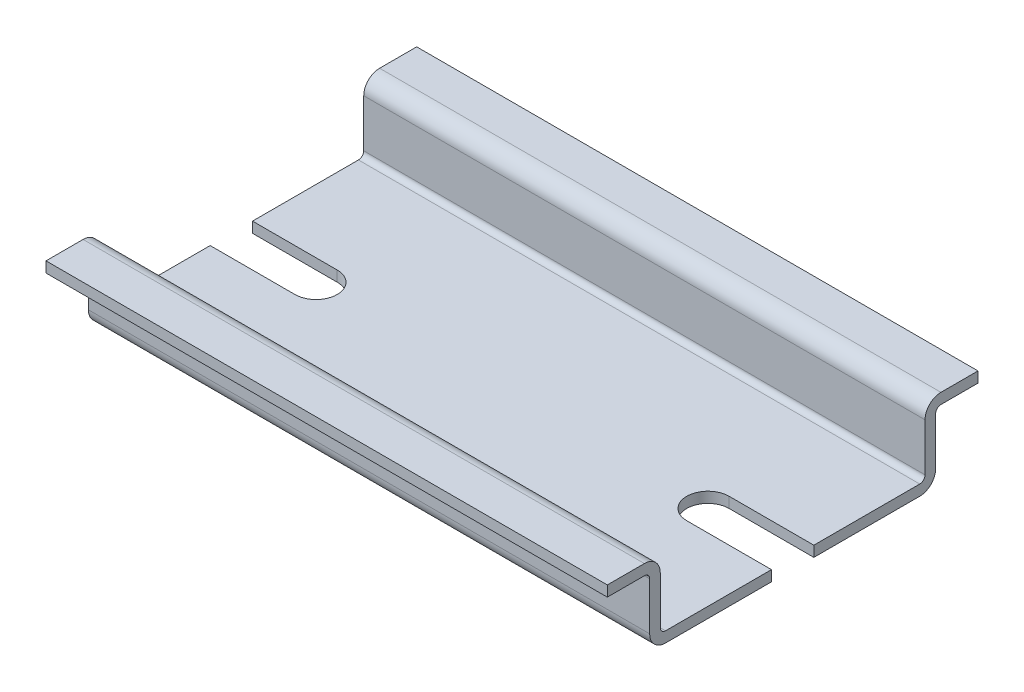
from build123d import *

# Parameters (mm, degrees)
BOSS_EXTRUDE1_DEPTH   = 26.5
CUT_EXTRUDE1_DEPTH    = 2
MIRROR17_COPY_1_DEPTH = 26.5
MIRROR17_COPY_2_DEPTH = 2


with BuildPart() as part:
    # Sketch1 → Boss-Extrude1 (new body)
    with BuildSketch(Plane(origin=(0, 0, 0), x_dir=(0, 0, -1), z_dir=(1, 0, 0))):
        with BuildLine():
            Line((0, 0), (-12, 0))
            ThreePointArc((-12, 0), (-13.060660172, 0.439339828), (-13.5, 1.5))
            Line((-13.5, 1.5), (-13.5, 6))
            ThreePointArc((-13.5, 6), (-13.646446609, 6.353553391), (-14, 6.5))
            Line((-14, 6.5), (-17.5, 6.5))
            Line((-17.5, 6.5), (-17.5, 7.5))
            Line((-17.5, 7.5), (-14, 7.5))
            ThreePointArc((-14, 7.5), (-12.939339828, 7.060660172), (-12.5, 6))
            Line((-12.5, 6), (-12.5, 1.5))
            ThreePointArc((-12.5, 1.5), (-12.353553391, 1.146446609), (-12, 1))
            Line((-12, 1), (0, 1))
            Line((0, 1), (0, 0))
        make_face()
    boss_extrude1 = extrude(amount=BOSS_EXTRUDE1_DEPTH)

    # Sketch3 → Cut-Extrude1 (cut, through all)
    with BuildSketch(Plane(origin=(0, 1, 0), x_dir=(1, 0, 0), z_dir=(0, 1, 0))):
        with BuildLine():
            Line((26.5, 0), (16.5, 0))
            ThreePointArc((16.5, 0), (17.085786438, -1.414213562), (18.5, -2))
            Line((18.5, -2), (26.5, -2))
            Line((26.5, -2), (26.5, 0))
        make_face()
    cut_extrude1 = extrude(amount=-CUT_EXTRUDE1_DEPTH, mode=Mode.SUBTRACT)

    # Mirror16: Boss-Extrude1, Cut-Extrude1 across plane
    add(boss_extrude1.mirror(Plane(origin=(0, 0, 0), x_dir=(0, 0, 1), z_dir=(1, 0, 0))))
    add(cut_extrude1.mirror(Plane(origin=(0, 0, 0), x_dir=(0, 0, 1), z_dir=(1, 0, 0))), mode=Mode.SUBTRACT)

    # Mirror17: Boss-Extrude1, Cut-Extrude1 across plane
    add(boss_extrude1.mirror(Plane.XY))
    add(cut_extrude1.mirror(Plane.XY), mode=Mode.SUBTRACT)

    # Mirror17 copy 1 sketch → Mirror17 copy 1 (add)
    with BuildSketch(Plane.ZY):
        with BuildLine():
            Line((0, 0), (-12, 0))
            ThreePointArc((-12, 0), (-13.060660172, 0.439339828), (-13.5, 1.5))
            Line((-13.5, 1.5), (-13.5, 6))
            ThreePointArc((-13.5, 6), (-13.646446609, 6.353553391), (-14, 6.5))
            Line((-14, 6.5), (-17.5, 6.5))
            Line((-17.5, 6.5), (-17.5, 7.5))
            Line((-17.5, 7.5), (-14, 7.5))
            ThreePointArc((-14, 7.5), (-12.939339828, 7.060660172), (-12.5, 6))
            Line((-12.5, 6), (-12.5, 1.5))
            ThreePointArc((-12.5, 1.5), (-12.353553391, 1.146446609), (-12, 1))
            Line((-12, 1), (0, 1))
            Line((0, 1), (0, 0))
        make_face()
    extrude(amount=MIRROR17_COPY_1_DEPTH)

    # Mirror17 copy 2 sketch → Mirror17 copy 2 (cut, through all)
    with BuildSketch(Plane(origin=(0, 1, 0), x_dir=(-1, 0, 0), z_dir=(0, 1, 0))):
        with BuildLine():
            Line((26.5, 0), (16.5, 0))
            ThreePointArc((16.5, 0), (17.085786438, -1.414213562), (18.5, -2))
            Line((18.5, -2), (26.5, -2))
            Line((26.5, -2), (26.5, 0))
        make_face()
    extrude(amount=-MIRROR17_COPY_2_DEPTH, mode=Mode.SUBTRACT)


solid = part.part
